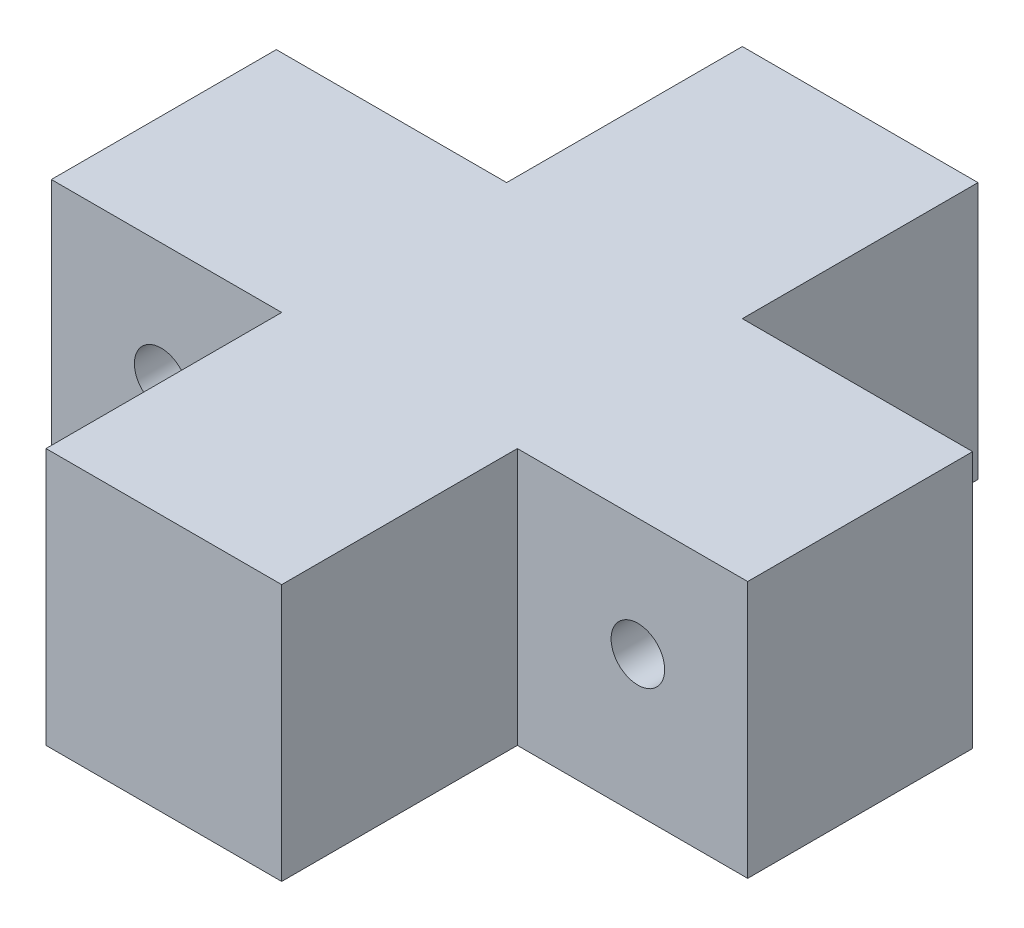
from build123d import *

# Parameters (mm, degrees)
SKETCH1_W               = 65
SKETCH1_H               = 65
BOSS_EXTRUDE1_DEPTH     = 24
SKETCH3_W               = 21.5
SKETCH3_H               = 22
CUT_EXTRUDE2_DEPTH      = 25
SKETCH4_R               = 2.5
CUT_EXTRUDE3_DEPTH      = 33.5
CUT_EXTRUDE3_DEPTH_BACK = 33.5


with BuildPart() as part:
    # Sketch1 → Boss-Extrude1 (new body)
    with BuildSketch(Plane(origin=(0, 0, 0), x_dir=(1, 0, 0), z_dir=(0, 1, 0))):
        Rectangle(SKETCH1_W, SKETCH1_H)
    extrude(amount=BOSS_EXTRUDE1_DEPTH)

    # Sketch3 → Cut-Extrude2 (cut, through all)
    with BuildSketch(Plane(origin=(0, 24, 0), x_dir=(1, 0, 0), z_dir=(0, 1, 0))):
        with Locations((-21.75, 21.5)):
            Rectangle(SKETCH3_W, SKETCH3_H)
        with Locations((21.75, 21.5)):
            Rectangle(SKETCH3_W, SKETCH3_H)
        with Locations((21.75, -21.5)):
            Rectangle(SKETCH3_W, SKETCH3_H)
        with Locations((-21.75, -21.5)):
            Rectangle(SKETCH3_W, SKETCH3_H)
    extrude(amount=-CUT_EXTRUDE2_DEPTH, mode=Mode.SUBTRACT)

    # Sketch4 → Cut-Extrude3 (cut, two sides)
    with BuildSketch(Plane.XY) as cut_extrude3_sk:
        with Locations((-22.25, 13)):
            Circle(SKETCH4_R)
        with Locations((22.25, 13)):
            Circle(SKETCH4_R)
    extrude(amount=CUT_EXTRUDE3_DEPTH, mode=Mode.SUBTRACT)
    extrude(cut_extrude3_sk.sketch, amount=-CUT_EXTRUDE3_DEPTH_BACK, mode=Mode.SUBTRACT)


solid = part.part
